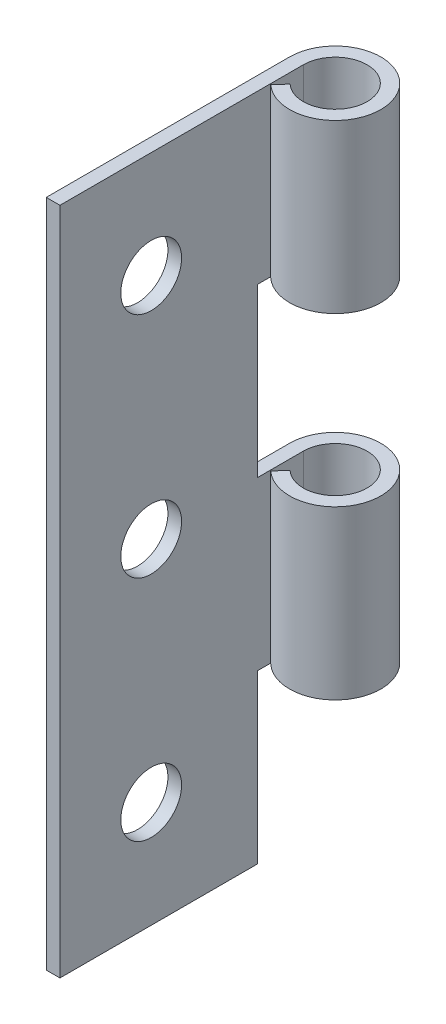
from build123d import *

# Parameters (mm, degrees)
SKETCH1_W           = 13
SKETCH1_H           = 44
BOSS_EXTRUDE1_DEPTH = 0.9
BOSS_EXTRUDE2_DEPTH = 44
SKETCH3_R           = 2
SKETCH3_W           = 6
SKETCH3_H           = 11
CUT_EXTRUDE1_DEPTH  = 127


with BuildPart() as part:
    # Sketch1 → Boss-Extrude1 (new body)
    with BuildSketch(Plane(origin=(0, 0, 0), x_dir=(0, 0, -1), z_dir=(1, 0, 0))):
        with Locations((6.5, 22)):
            Rectangle(SKETCH1_W, SKETCH1_H)
    extrude(amount=BOSS_EXTRUDE1_DEPTH)

    # Sketch2 → Boss-Extrude2 (add)
    with BuildSketch(Plane.XZ):
        with BuildLine():
            Line((0, -16), (0, -13))
            Line((0, -13), (0.9, -13))
            Line((0.9, -13), (0.9, -16))
            ThreePointArc((0.9, -16), (4.925639318, -16.837802611), (1.568488776, -14.46351843))
            Line((1.568488776, -14.46351843), (0.954983966, -13.805026328))
            ThreePointArc((0.954983966, -13.805026328), (5.750913312, -17.196860873), (0, -16))
        make_face()
    extrude(amount=-BOSS_EXTRUDE2_DEPTH)

    # Sketch3 → Cut-Extrude1 (cut)
    with BuildSketch(Plane.ZY):
        with Locations((-6, 7)):
            Circle(SKETCH3_R)
        with Locations((-6, 22)):
            Circle(SKETCH3_R)
        with Locations((-6, 37)):
            Circle(SKETCH3_R)
        with Locations((-16, 5.5)):
            Rectangle(SKETCH3_W, SKETCH3_H)
        with Locations((-16, 27.5)):
            Rectangle(SKETCH3_W, SKETCH3_H)
    extrude(amount=-CUT_EXTRUDE1_DEPTH, mode=Mode.SUBTRACT)


solid = part.part
